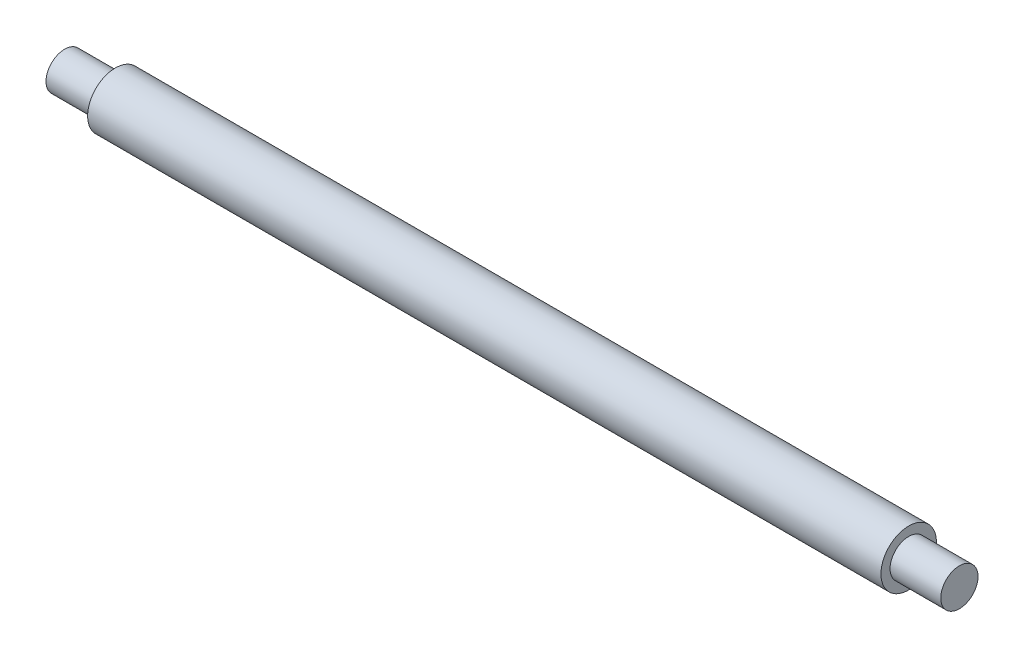
from build123d import *


with BuildPart() as part:
    # Sketch1 → Revolve1 (revolve)
    with BuildSketch(Plane.XY):
        Polygon((76.2, 0), (76.2, 3.175), (67.564, 3.175), (67.564, 4.7244), (-67.564, 4.7244), (-67.564, 3.175), (-76.2, 3.175), (-76.2, 0), align=None)
    revolve(axis=Axis((-76.2, 0, 0), (1, 0, 0)))


solid = part.part
